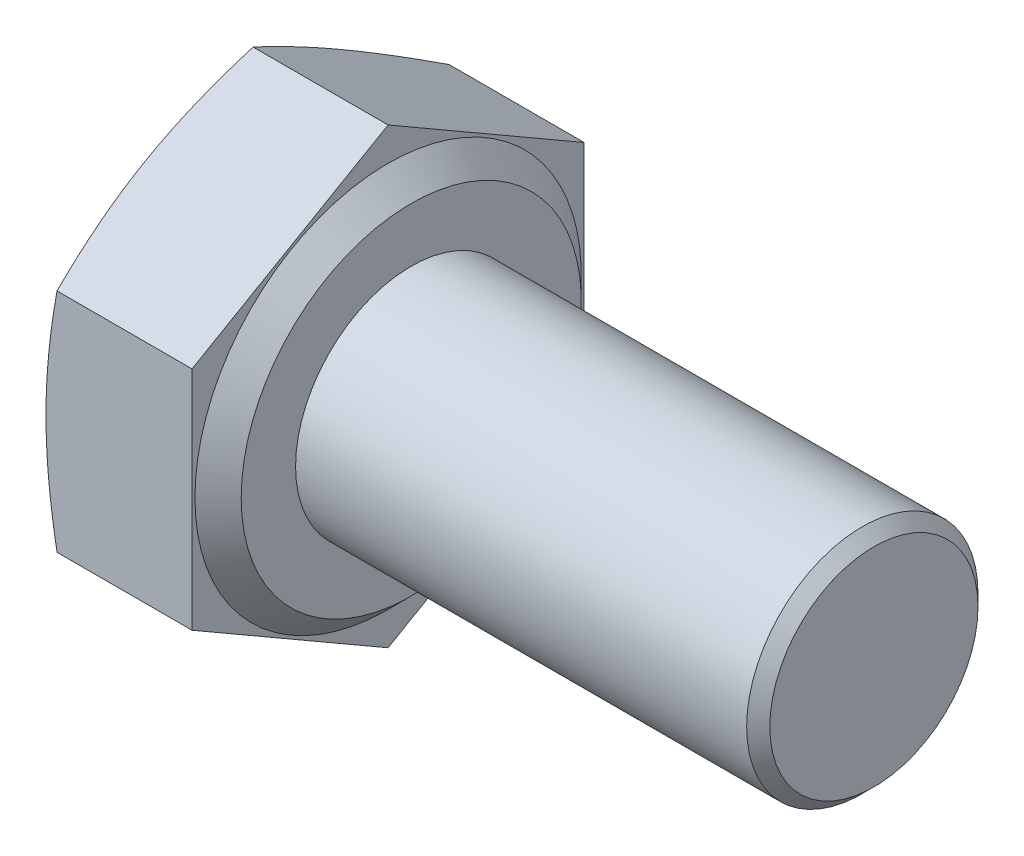
from build123d import *

# Parameters (mm, degrees)
BASEHEAD_DEPTH = 2.925
SKETCH5_R      = 2
BASEBODY_DEPTH = 8
CHAMFER1_SIZE  = 0.2


with BuildPart() as part:
    # Sketch2 → BaseHead (new body)
    with BuildSketch(Plane(origin=(0, 0, 0), x_dir=(0, 0, -1), z_dir=(1, 0, 0))):
        Polygon((3.39, -1.957217413), (3.39, 1.957217413), (0, 3.914434825), (-3.39, 1.957217413), (-3.39, -1.957217413), (0, -3.914434825), align=None)
    extrude(amount=BASEHEAD_DEPTH)

    # Sketch3 → BearingFace (revolve, cut)
    with BuildSketch(Plane.XY):
        Polygon((2.925, 3.914434825), (2.925, 2.94), (2.525, 3.34), (2.525, 3.914434825), align=None)
    revolve(axis=Axis((-0.957090588, 0, 0), (1, 0, 0)), mode=Mode.SUBTRACT)

    # Sketch4 → HeadChamfer (revolve, cut)
    with BuildSketch(Plane.XY):
        Polygon((0, 3.914434825), (0.190878666, 3.914434825), (0, 3.39), align=None)
    revolve(axis=Axis((-0.493528746, 0, 0), (1, 0, 0)), mode=Mode.SUBTRACT)

    # Sketch5 → BaseBody (add)
    with BuildSketch(Plane(origin=(2.925, 0, 0), x_dir=(0, 0, -1), z_dir=(1, 0, 0))):
        Circle(SKETCH5_R)
    extrude(amount=BASEBODY_DEPTH)

    # Chamfer1
    chamfer1_edges = [part.edges().sort_by_distance(p)[0] for p in [
        (10.925, 0, 2),
    ]]
    chamfer(chamfer1_edges, length=CHAMFER1_SIZE)


solid = part.part
